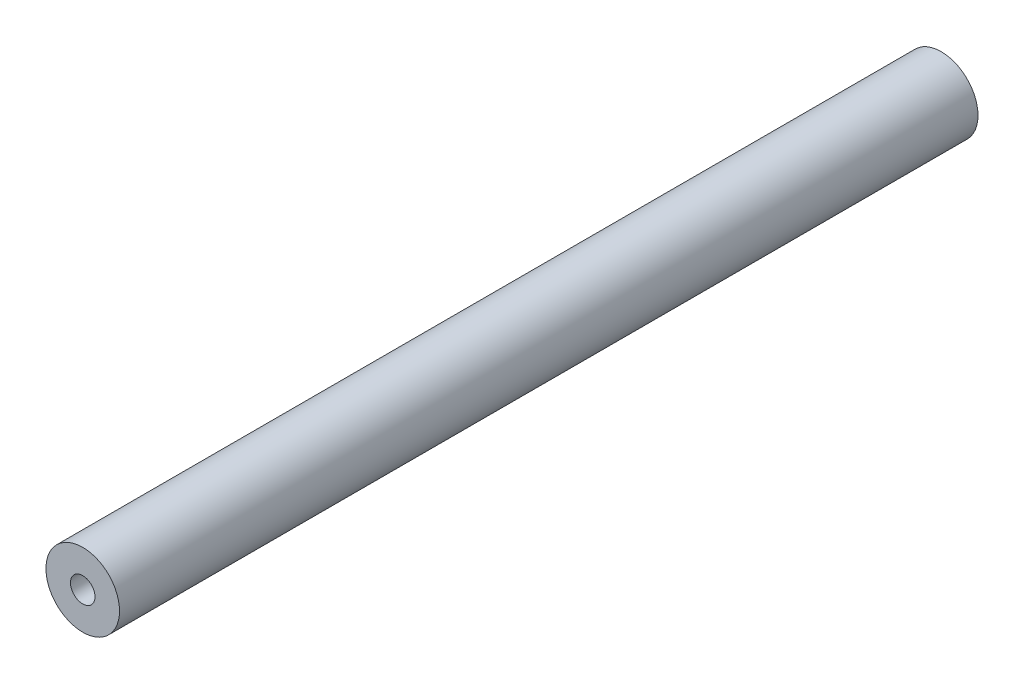
from build123d import *

# Parameters (mm, degrees)
SKETCH1_R           = 3
SKETCH1_R_2         = 1
EXTRUDE_THIN1_DEPTH = 70


with BuildPart() as part:
    # Sketch1 → Extrude-Thin1 (new body)
    with BuildSketch(Plane.XY):
        Circle(SKETCH1_R)
        Circle(SKETCH1_R_2, mode=Mode.SUBTRACT)
    extrude(amount=EXTRUDE_THIN1_DEPTH)


solid = part.part
